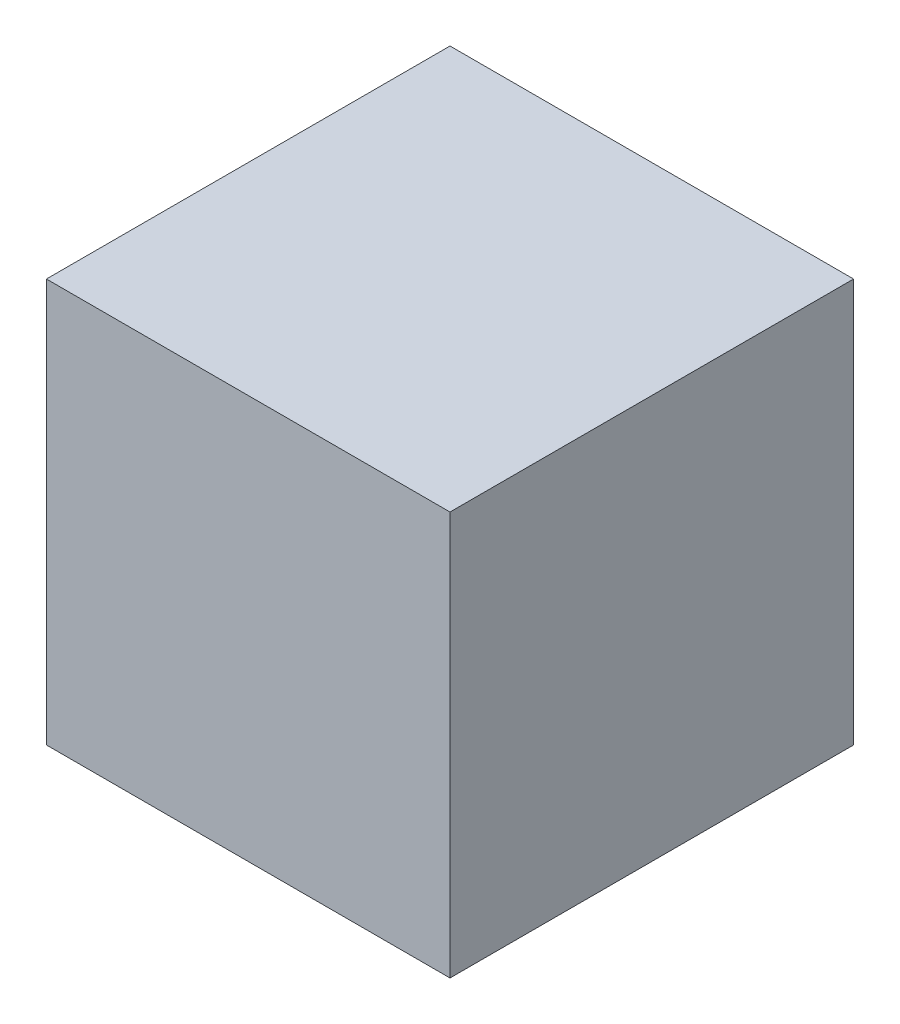
from build123d import *

# Parameters (mm, degrees)
SKETCH1_W           = 53.975
SKETCH1_H           = 53.975
BOSS_EXTRUDE1_DEPTH = 26.9875


with BuildPart() as part:
    # Sketch1 → Boss-Extrude1 (new body, symmetric)
    with BuildSketch(Plane(origin=(0, 0, 0), x_dir=(1, 0, 0), z_dir=(0, 1, 0))):
        Rectangle(SKETCH1_W, SKETCH1_H)
    extrude(amount=BOSS_EXTRUDE1_DEPTH, both=True)


solid = part.part
